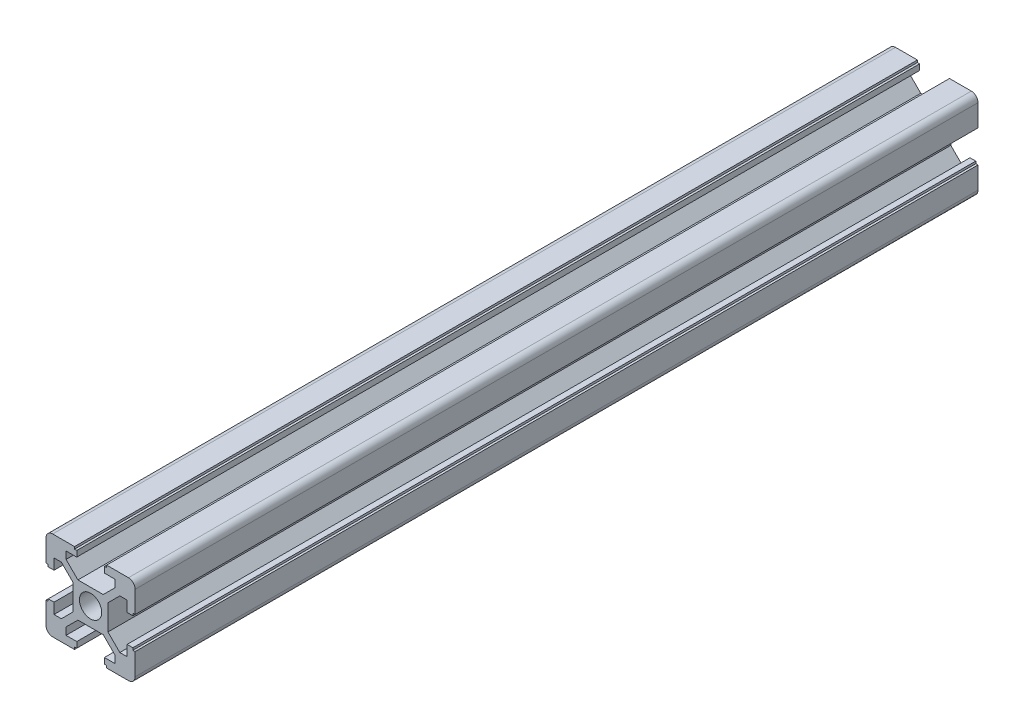
from build123d import *

# Parameters (mm, degrees)
SKETCH1_R           = 2.5
BOSS_EXTRUDE1_DEPTH = 189.096108091
SCALE_2_SCALE       = 3
SCALE_3_SCALE       = 6
SCALE_5_SCALE       = 2
SCALE_6_SCALE       = 0.25
SCALE_7_SCALE       = 0.125
SCALE_8_SCALE       = 0.25
SCALE_9_SCALE       = 4
SCALE_10_SCALE      = 4
SCALE_11_SCALE      = 0.111111111


with BuildPart() as part:
    # Sketch1 → Boss-Extrude1 (new body)
    with BuildSketch(Plane.XY):
        with BuildLine():
            Line((2.839339828, 3.9), (5.5, 6.560660172))
            Line((5.5, 6.560660172), (5.5, 8.2))
            Line((5.5, 8.2), (3.1, 8.2))
            Line((3.1, 8.2), (3.1, 9.5))
            Line((3.1, 9.5), (3.6, 9.5))
            Line((3.6, 9.5), (3.6, 10))
            Line((3.6, 10), (8.5, 10))
            ThreePointArc((8.5, 10), (9.560660172, 9.560660172), (10, 8.5))
            Line((10, 8.5), (10, 3.6))
            Line((10, 3.6), (9.5, 3.6))
            Line((9.5, 3.6), (9.5, 3.1))
            Line((9.5, 3.1), (8.2, 3.1))
            Line((8.2, 3.1), (8.2, 5.5))
            Line((8.2, 5.5), (6.560660172, 5.5))
            Line((6.560660172, 5.5), (3.9, 2.839339828))
            Line((3.9, 2.839339828), (3.9, -2.839339828))
            Line((3.9, -2.839339828), (6.560660172, -5.5))
            Line((6.560660172, -5.5), (8.2, -5.5))
            Line((8.2, -5.5), (8.2, -3.1))
            Line((8.2, -3.1), (9.5, -3.1))
            Line((9.5, -3.1), (9.5, -3.6))
            Line((9.5, -3.6), (10, -3.6))
            Line((10, -3.6), (10, -8.5))
            ThreePointArc((10, -8.5), (9.560660172, -9.560660172), (8.5, -10))
            Line((8.5, -10), (3.6, -10))
            Line((3.6, -10), (3.6, -9.5))
            Line((3.6, -9.5), (3.1, -9.5))
            Line((3.1, -9.5), (3.1, -8.2))
            Line((3.1, -8.2), (5.5, -8.2))
            Line((5.5, -8.2), (5.5, -6.560660172))
            Line((5.5, -6.560660172), (2.839339828, -3.9))
            Line((2.839339828, -3.9), (-2.839339828, -3.9))
            Line((-2.839339828, -3.9), (-5.5, -6.560660172))
            Line((-5.5, -6.560660172), (-5.5, -8.2))
            Line((-5.5, -8.2), (-3.1, -8.2))
            Line((-3.1, -8.2), (-3.1, -9.5))
            Line((-3.1, -9.5), (-3.6, -9.5))
            Line((-3.6, -9.5), (-3.6, -10))
            Line((-3.6, -10), (-8.5, -10))
            ThreePointArc((-8.5, -10), (-9.560660172, -9.560660172), (-10, -8.5))
            Line((-10, -8.5), (-10, -3.6))
            Line((-10, -3.6), (-9.5, -3.6))
            Line((-9.5, -3.6), (-9.5, -3.1))
            Line((-9.5, -3.1), (-8.2, -3.1))
            Line((-8.2, -3.1), (-8.2, -5.5))
            Line((-8.2, -5.5), (-6.560660172, -5.5))
            Line((-6.560660172, -5.5), (-3.9, -2.839339828))
            Line((-3.9, -2.839339828), (-3.9, 2.839339828))
            Line((-3.9, 2.839339828), (-6.560660172, 5.5))
            Line((-6.560660172, 5.5), (-8.2, 5.5))
            Line((-8.2, 5.5), (-8.2, 3.1))
            Line((-8.2, 3.1), (-9.5, 3.1))
            Line((-9.5, 3.1), (-9.5, 3.6))
            Line((-9.5, 3.6), (-10, 3.6))
            Line((-10, 3.6), (-10, 8.5))
            ThreePointArc((-10, 8.5), (-9.560660172, 9.560660172), (-8.5, 10))
            Line((-8.5, 10), (-3.6, 10))
            Line((-3.6, 10), (-3.6, 9.5))
            Line((-3.6, 9.5), (-3.1, 9.5))
            Line((-3.1, 9.5), (-3.1, 8.2))
            Line((-3.1, 8.2), (-5.5, 8.2))
            Line((-5.5, 8.2), (-5.5, 6.560660172))
            Line((-5.5, 6.560660172), (-2.839339828, 3.9))
            Line((-2.839339828, 3.9), (2.839339828, 3.9))
        make_face()
        with Locations((0, 0.235847297)):
            Circle(SKETCH1_R, mode=Mode.SUBTRACT)
    extrude(amount=BOSS_EXTRUDE1_DEPTH)


with BuildPart() as part_1:
    # 缩放比例2: scaled about (0, -0.027095247, 94.548054046)
    add(part.part.scale(SCALE_2_SCALE).moved(Location((0, 0.054190494, -189.096108092))))


with BuildPart() as part_2:
    # 缩放比例3: scaled about (0, -0.027095247, 94.548054045)
    add(part_1.part.scale(SCALE_3_SCALE).moved(Location((0, 0.135476235, -472.740270225))))


with BuildPart() as part_3:
    # 缩放比例5: scaled about (0, -0.027095249, 94.548054043)
    add(part_2.part.scale(SCALE_5_SCALE).moved(Location((0, 0.027095249, -94.548054043))))


with BuildPart() as part_4:
    # 缩放比例6: scaled about (0, -0.027095249, 94.548054044)
    add(part_3.part.scale(SCALE_6_SCALE).moved(Location((0, -0.020321437, 70.911040533))))


with BuildPart() as part_5:
    # 缩放比例7: scaled about (0, -0.027095249, 94.548054044)
    add(part_4.part.scale(SCALE_7_SCALE).moved(Location((0, -0.023708343, 82.729547289))))


with BuildPart() as part_6:
    # 缩放比例8: scaled about (0, -0.027095249, 94.548054044)
    add(part_5.part.scale(SCALE_8_SCALE).moved(Location((0, -0.020321437, 70.911040533))))


with BuildPart() as part_7:
    # 缩放比例9: scaled about (0, -0.027095249, 94.548054044)
    add(part_6.part.scale(SCALE_9_SCALE).moved(Location((0, 0.081285747, -283.644162132))))


with BuildPart() as part_8:
    # 缩放比例10: scaled about (0, -0.027095249, 94.548054044)
    add(part_7.part.scale(SCALE_10_SCALE).moved(Location((0, 0.081285747, -283.644162132))))


with BuildPart() as part_9:
    # 缩放比例11: scaled about (0, -0.027095249, 94.548054044)
    add(part_8.part.scale(SCALE_11_SCALE).moved(Location((0, -0.024084666, 84.042714706))))


solid = part_9.part
